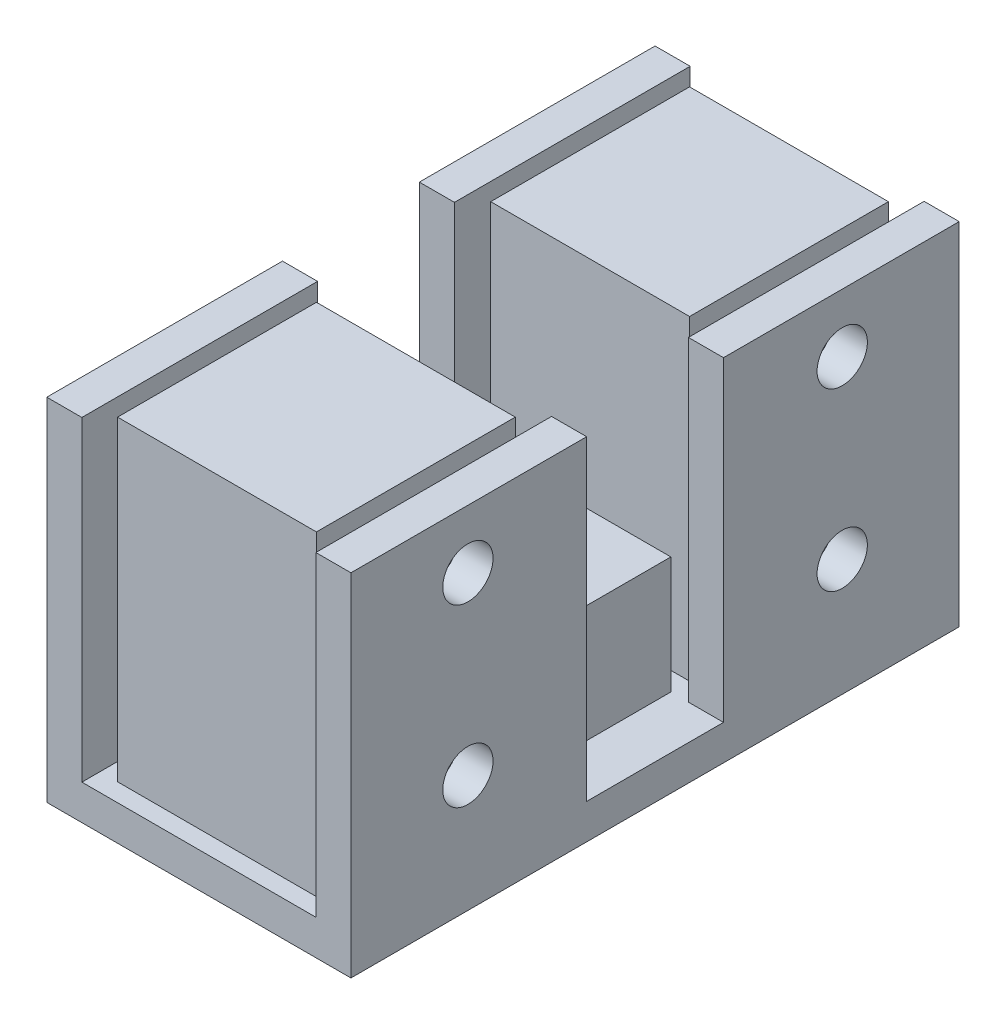
from build123d import *

# Parameters (mm, degrees)
SKETCH1_W           = 26
SKETCH1_H           = 52
BOSS_EXTRUDE1_DEPTH = 30
SKETCH2_W           = 1.5
SKETCH2_H           = 27
CUT_EXTRUDE1_DEPTH  = 53
SKETCH3_OUTSIDE_W   = 41.084
SKETCH3_OUTSIDE_H   = 67.084
SKETCH3_OUTSIDE_W_2 = 17
SKETCH3_OUTSIDE_H_2 = 17
SKETCH3_OUTSIDE_H_3 = 11.7
SKETCH3_OUTSIDE_W_3 = 3
SKETCH3_OUTSIDE_H_4 = 20.15
CUT_EXTRUDE2_DEPTH  = 27
SKETCH4_W           = 17
SKETCH4_H           = 11.7
CUT_EXTRUDE3_DEPTH  = 17
SKETCH5_R           = 2.15
CUT_EXTRUDE4_DEPTH  = 27


with BuildPart() as part:
    # Sketch1 → Boss-Extrude1 (new body)
    with BuildSketch(Plane(origin=(0, 0, 0), x_dir=(1, 0, 0), z_dir=(0, 1, 0))):
        with Locations((13, 26)):
            Rectangle(SKETCH1_W, SKETCH1_H)
    extrude(amount=BOSS_EXTRUDE1_DEPTH)

    # Sketch2 → Cut-Extrude1 (cut, through all)
    with BuildSketch(Plane(origin=(0, 0, -52), x_dir=(-1, 0, 0), z_dir=(0, 0, -1))):
        with Locations((-22.25, 16.5)):
            Rectangle(SKETCH2_W, SKETCH2_H)
        with Locations((-3.75, 16.5)):
            Rectangle(SKETCH2_W, SKETCH2_H)
    extrude(amount=-CUT_EXTRUDE1_DEPTH, mode=Mode.SUBTRACT)

    # Sketch3 outside → Cut-Extrude2 (cut)
    with BuildSketch(Plane(origin=(0, 30, 0), x_dir=(1, 0, 0), z_dir=(0, 1, 0))):
        with Locations((13, 26)):
            Rectangle(SKETCH3_OUTSIDE_W, SKETCH3_OUTSIDE_H)
        with Locations((13, 41.95)):
            Rectangle(SKETCH3_OUTSIDE_W_2, SKETCH3_OUTSIDE_H_2, mode=Mode.SUBTRACT)
        with Locations((13, 26)):
            Rectangle(SKETCH3_OUTSIDE_W_2, SKETCH3_OUTSIDE_H_3, mode=Mode.SUBTRACT)
        with Locations((13, 10.05)):
            Rectangle(SKETCH3_OUTSIDE_W_2, SKETCH3_OUTSIDE_H_2, mode=Mode.SUBTRACT)
        with Locations((1.5, 41.925)):
            Rectangle(SKETCH3_OUTSIDE_W_3, SKETCH3_OUTSIDE_H_4, mode=Mode.SUBTRACT)
        with Locations((24.5, 41.925)):
            Rectangle(SKETCH3_OUTSIDE_W_3, SKETCH3_OUTSIDE_H_4, mode=Mode.SUBTRACT)
        with Locations((1.5, 10.075)):
            Rectangle(SKETCH3_OUTSIDE_W_3, SKETCH3_OUTSIDE_H_4, mode=Mode.SUBTRACT)
        with Locations((24.5, 10.075)):
            Rectangle(SKETCH3_OUTSIDE_W_3, SKETCH3_OUTSIDE_H_4, mode=Mode.SUBTRACT)
    extrude(amount=-CUT_EXTRUDE2_DEPTH, mode=Mode.SUBTRACT)

    # Sketch4 → Cut-Extrude3 (cut)
    with BuildSketch(Plane(origin=(0, 30, 0), x_dir=(1, 0, 0), z_dir=(0, 1, 0))):
        with Locations((13, 26)):
            Rectangle(SKETCH4_W, SKETCH4_H)
    extrude(amount=-CUT_EXTRUDE3_DEPTH, mode=Mode.SUBTRACT)

    # Sketch5 → Cut-Extrude4 (cut, through all)
    with BuildSketch(Plane.ZY):
        with Locations((-42, 25)):
            Circle(SKETCH5_R)
        with Locations((-42, 10)):
            Circle(SKETCH5_R)
        with Locations((-10, 25)):
            Circle(SKETCH5_R)
        with Locations((-10, 10)):
            Circle(SKETCH5_R)
    extrude(amount=-CUT_EXTRUDE4_DEPTH, mode=Mode.SUBTRACT)


solid = part.part
